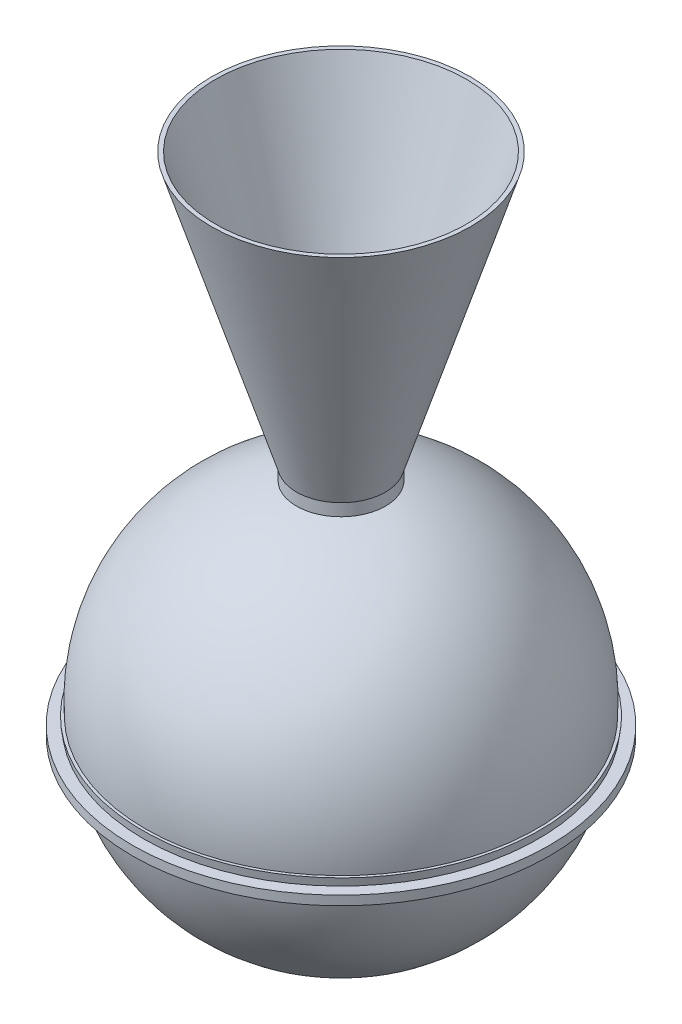
from build123d import *


with BuildPart() as part:
    # Sketch1 → Revolve-Thin2 (revolve)
    with BuildSketch(Plane.XY):
        with BuildLine():
            ThreePointArc((0, -286.742610421), (182.45299837, -221.206301937), (281.505096069, -54.554610421))
            Line((281.505096069, -54.554610421), (285.505096069, -54.554610421))
            Line((285.505096069, -54.554610421), (287.015973703, -43.064610421))
            Line((287.015973703, -43.064610421), (305, -43.064610421))
            Line((305, -43.064610421), (305, -31.564610421))
            Line((305, -31.564610421), (288.528166287, -31.564610421))
            Line((288.528166287, -31.564610421), (290.039043921, -20.074610421))
            Line((290.039043921, -20.074610421), (286.039043921, -20.074610421))
            ThreePointArc((286.039043921, -20.074610421), (230.474900515, 170.594973149), (64.35, 279.428706705))
            Line((64.35, 279.428706705), (64.35, 298.232610421))
            Line((64.35, 298.232610421), (188.95, 697.032610421))
            Line((188.95, 697.032610421), (184.95, 697.032610421))
            Line((184.95, 697.032610421), (70.68606436, 360.809395967))
            ThreePointArc((70.68606436, 360.809395967), (60.780146491, 341.167559177), (45.066208841, 325.772718327))
            ThreePointArc((45.066208841, 325.772718327), (33.288926302, 285.366692434), (70.188097559, 265.123113871))
            ThreePointArc((70.188097559, 265.123113871), (90.390180269, 265.602713712), (109.82288481, 260.05977622))
            Line((109.82288481, 260.05977622), (123.05564488, 254.559800461))
            Line((123.05564488, 254.559800461), (122.671842713, 253.636385118))
            Line((122.671842713, 253.636385118), (109.422978506, 259.143054292))
            ThreePointArc((109.422978506, 259.143054292), (90.27204525, 264.609677885), (70.361745737, 264.138306118))
            ThreePointArc((70.361745737, 264.138306118), (32.36504677, 284.984009001), (44.492632405, 326.591870371))
            ThreePointArc((44.492632405, 326.591870371), (59.976574204, 341.762798813), (69.735246401, 361.119395632))
            Line((69.735246401, 361.119395632), (184.233675528, 698.032610421))
            Line((184.233675528, 698.032610421), (190.310109529, 698.032610421))
            Line((190.310109529, 698.032610421), (65.35, 298.080028719))
            Line((65.35, 298.080028719), (65.35, 280.223459674))
            ThreePointArc((65.35, 280.223459674), (231.19643255, 171.30096155), (287.109681288, -19.074610421))
            Line((287.109681288, -19.074610421), (291.179147345, -19.074610421))
            Line((291.179147345, -19.074610421), (289.668269711, -30.564610421))
            Line((289.668269711, -30.564610421), (306, -30.564610421))
            Line((306, -30.564610421), (306, -44.064610421))
            Line((306, -44.064610421), (287.893087112, -44.064610421))
            Line((287.893087112, -44.064610421), (286.382209478, -55.554610421))
            Line((286.382209478, -55.554610421), (282.328700477, -55.554610421))
            ThreePointArc((282.328700477, -55.554610421), (182.770869162, -222.240003684), (0, -287.742610421))
            Line((0, -287.742610421), (0, -286.742610421))
        make_face()
    revolve(axis=Axis((0, -286.742610421, 0), (0, 1, 0)))


solid = part.part
